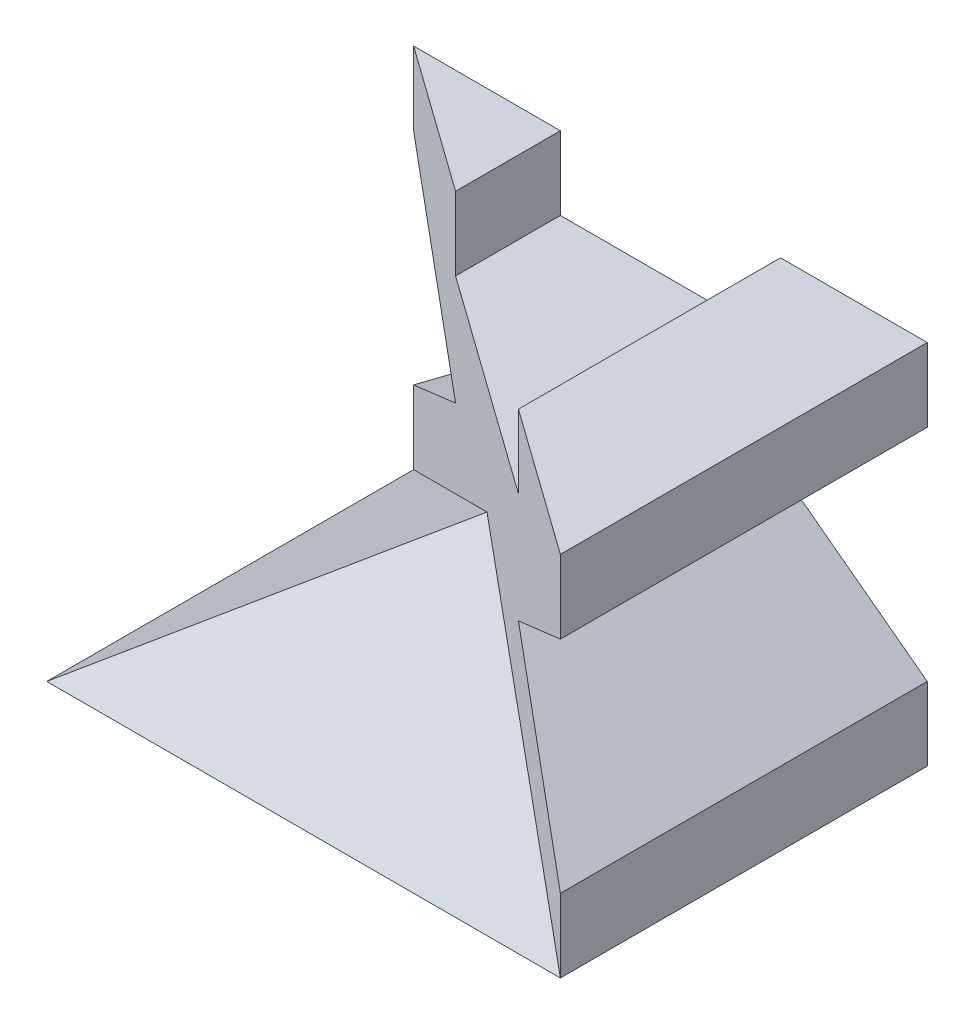
from build123d import *

# Parameters (mm, degrees)
BOSS_EXTRUDE1_DEPTH = 5
CUT_EXTRUDE1_DEPTH  = 5
BOSS_EXTRUDE2_DEPTH = 2.5
CUT_EXTRUDE2_DEPTH  = 2.5
CUT_EXTRUDE3_DEPTH  = 2.5


with BuildPart() as part:
    # Sketch1 → Boss-Extrude1 (new body)
    with BuildSketch(Plane.XY):
        Polygon((-3.5, -2.5), (3.5, -2.5), (3.5, -1.5), (1.5, 0), (3.5, 1.5), (3.5, 2.5), (1.5, 2.5), (1.5, 1.5), (-1.5, 1.5), (-1.5, 2.5), (-3.5, 2.5), (-3.5, 1.5), (-1.5, 0), (-3.5, -1.5), align=None)
    extrude(amount=BOSS_EXTRUDE1_DEPTH)

    # Sketch2 → Cut-Extrude1 (cut)
    with BuildSketch(Plane(origin=(0, 2.5, 0), x_dir=(1, 0, 0), z_dir=(0, 1, 0))):
        Polygon((-3.5, 0), (3.5, -5), (-3.5, -5), align=None)
    extrude(amount=-CUT_EXTRUDE1_DEPTH, mode=Mode.SUBTRACT)

    # Sketch3 → Boss-Extrude2 (add)
    with BuildSketch(Plane.XZ.offset(2.5)):
        Polygon((-3.5, 0), (-3.5, 5), (3.5, 5), align=None)
    extrude(amount=-BOSS_EXTRUDE2_DEPTH)

    # 3DSketch2 → Cut-Extrude2 (cut, along a direction that is not the sketch's normal)
    with BuildSketch(Plane(origin=(-3.5, -2.5, 0), x_dir=(0, 0, 1), z_dir=(-0.5812381937190964, 0.8137334712067351, 0))):
        Polygon((0, 0), (2.5, 4.301162634), (5, 0), align=None)
    extrude(amount=CUT_EXTRUDE2_DEPTH, dir=(0, 1, 0), mode=Mode.SUBTRACT)

    # 3DSketch3 → Cut-Extrude3 (cut, along a direction that is not the sketch's normal)
    with BuildSketch(Plane(origin=(0, 0, 2.5), x_dir=(-0.7035264706814485, -0.502518907629606, 0.502518907629606), z_dir=(0, 0.7071067811865476, 0.7071067811865476))):
        Polygon((0, 0), (4.974937186, 0), (0.050251891, 4.974683382), align=None)
    extrude(amount=CUT_EXTRUDE3_DEPTH, dir=(0, 1, 0), mode=Mode.SUBTRACT)


solid = part.part
